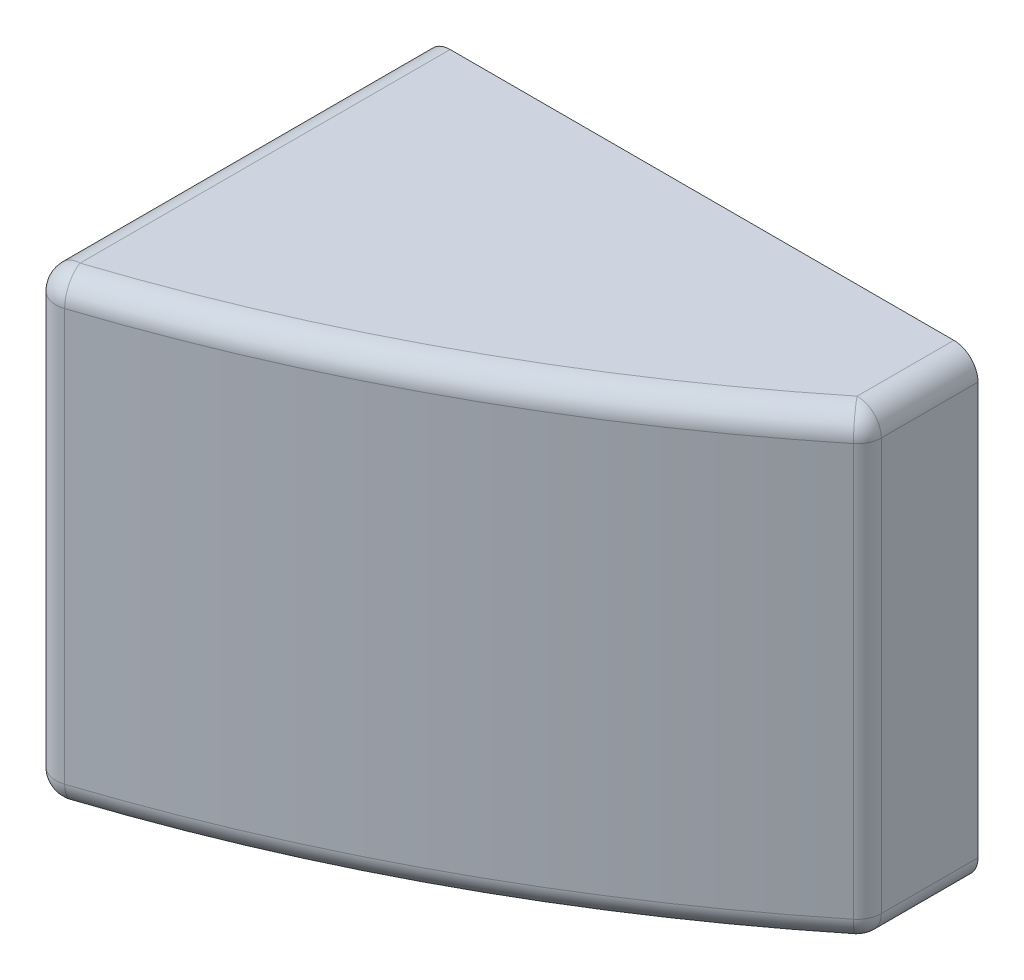
from build123d import *

# Parameters (mm, degrees)
SKETCH1_W           = 4.57
SKETCH1_H           = 3.81
BOSS_EXTRUDE1_DEPTH = 4
CUT_EXTRUDE1_DEPTH  = 10
FILLET1_R           = 0.2


with BuildPart() as part:
    # Sketch1 → Boss-Extrude1 (new body)
    with BuildSketch(Plane.XY):
        with Locations((2.285, 1.905)):
            Rectangle(SKETCH1_W, SKETCH1_H)
    extrude(amount=BOSS_EXTRUDE1_DEPTH)

    # Sketch2 → Cut-Extrude1 (cut)
    with BuildSketch(Plane.XZ):
        with BuildLine():
            ThreePointArc((0, 3.336462357), (2.404002198, 2.339004343), (4.57, 0.895881831))
            Line((4.57, 0.895881831), (4.57, 4))
            Line((4.57, 4), (0, 4))
            Line((0, 4), (0, 3.336462357))
        make_face()
    extrude(amount=-CUT_EXTRUDE1_DEPTH, mode=Mode.SUBTRACT)

    # Fillet1
    fillet1_edges = [part.edges().sort_by_distance(p)[0] for p in [
        (0, 3.81, 1.668231179),
        (4.57, 3.81, 0.447940916),
        (2.404002198, 3.81, 2.339004343),
        (4.57, 0, 0.447940916),
        (0, 0, 1.668231179),
        (4.57, 1.905, 0.895881831),
        (0, 1.905, 3.336462357),
        (2.404002198, 0, 2.339004343),
    ]]
    fillet(fillet1_edges, radius=FILLET1_R)


solid = part.part
